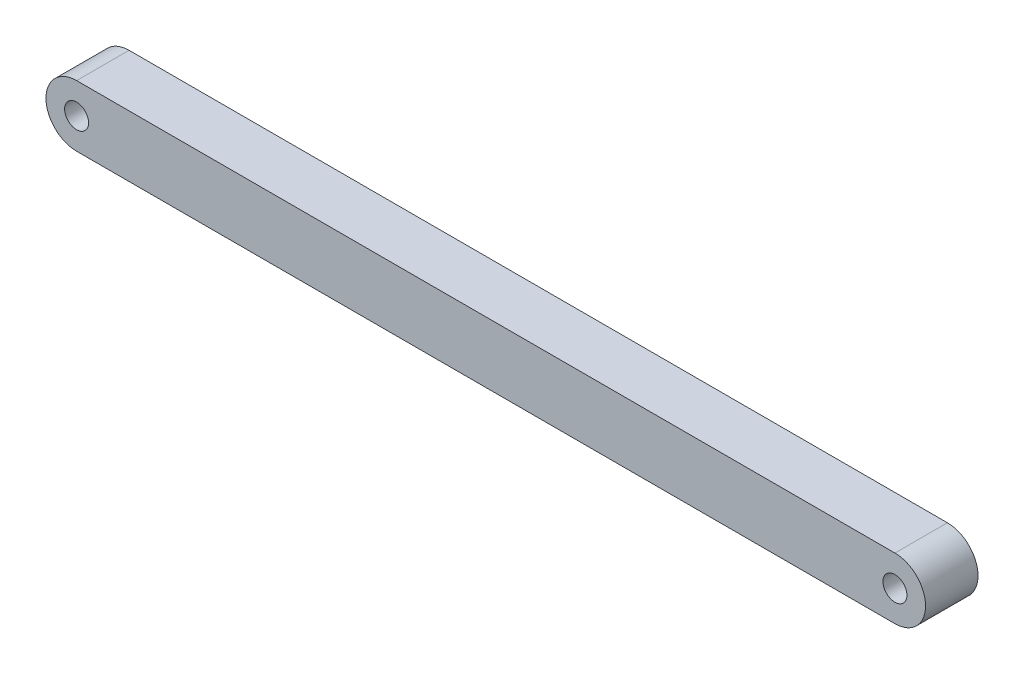
from build123d import *

# Parameters (mm, degrees)
BOSS_EXTRUDE1_DEPTH = 7.62
CUT_EXTRUDE1_START  = -8.62
SKETCH2_R           = 1.7399
CUT_EXTRUDE1_DEPTH  = 9.62


with BuildPart() as part:
    # Sketch1 → Boss-Extrude1 (new body)
    with BuildSketch(Plane.XY):
        with BuildLine():
            Line((0, 4.445), (118.872, 4.445))
            ThreePointArc((118.872, 4.445), (123.317, 0), (118.872, -4.445))
            Line((118.872, -4.445), (0, -4.445))
            ThreePointArc((0, -4.445), (-4.445, 0), (0, 4.445))
        make_face()
    extrude(amount=BOSS_EXTRUDE1_DEPTH)

    # Sketch2 → Cut-Extrude1 (cut)
    with BuildSketch(Plane.XY.offset(7.62).offset(CUT_EXTRUDE1_START)):
        Circle(SKETCH2_R)
    cut_extrude1 = extrude(amount=CUT_EXTRUDE1_DEPTH, mode=Mode.SUBTRACT)

    # Mirror1: Cut-Extrude1 across plane
    add(cut_extrude1.mirror(Plane(origin=(59.436, 0, 0), x_dir=(0, 0, 1), z_dir=(1, 0, 0))), mode=Mode.SUBTRACT)


solid = part.part
